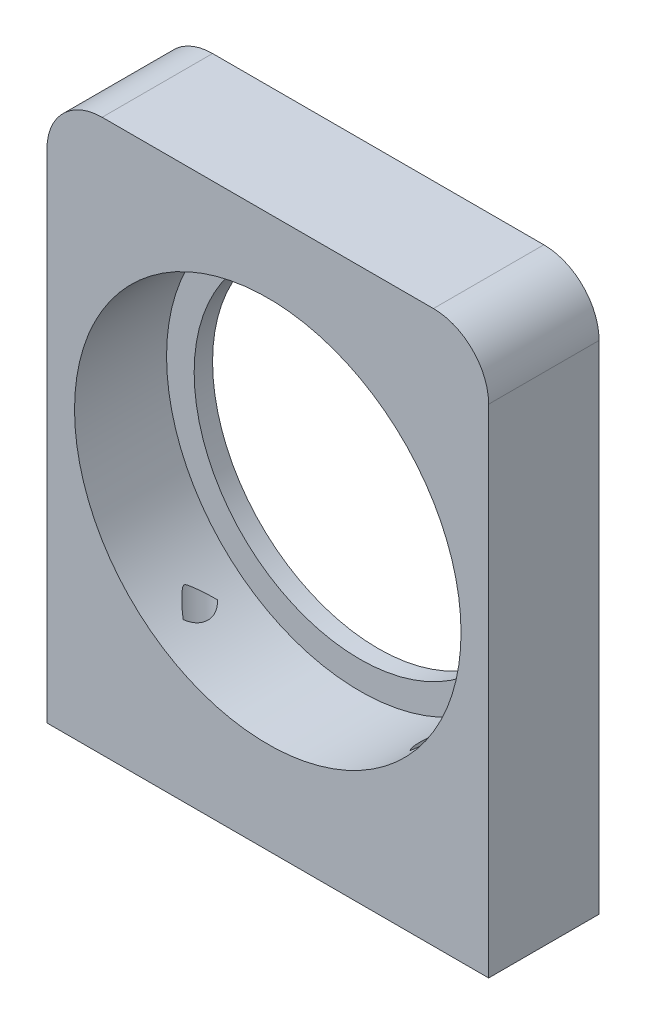
from build123d import *

# Parameters (mm, degrees)
SKIZZE1_W                       = 24
SKIZZE1_H                       = 30
AUFSATZ_LINEAR_AUSTRAGEN1_DEPTH = 3
SKIZZE2_R                       = 10.5
SCHNITT_LINEAR_AUSTRAGEN2_DEPTH = 5
SKIZZE2_3_R                     = 9
SCHNITT_LINEAR_AUSTRAGEN3_DEPTH = 7
VERRUNDUNG1_R                   = 3
M3_GEWINDEBOHRUNG1_D            = 2.5
M3_GEWINDEBOHRUNG1_DEPTH        = 7
M3_GEWINDEBOHRUNG1_TIP          = 0.751075774


with BuildPart() as part:
    # Skizze1 → Aufsatz-Linear austragen1 (new body, symmetric)
    with BuildSketch(Plane.XY):
        with Locations((0, 15)):
            Rectangle(SKIZZE1_W, SKIZZE1_H)
    extrude(amount=AUFSATZ_LINEAR_AUSTRAGEN1_DEPTH, both=True)

    # Skizze2 → Schnitt-Linear austragen2 (cut)
    with BuildSketch(Plane.XY.offset(3)):
        with Locations((0, 15.5)):
            Circle(SKIZZE2_R)
    extrude(amount=-SCHNITT_LINEAR_AUSTRAGEN2_DEPTH, mode=Mode.SUBTRACT)

    # Skizze2_3 → Schnitt-Linear austragen3 (cut, through all)
    with BuildSketch(Plane.XY.offset(3)):
        with Locations((0, 15.5)):
            Circle(SKIZZE2_3_R)
    extrude(amount=-SCHNITT_LINEAR_AUSTRAGEN3_DEPTH, mode=Mode.SUBTRACT)

    # Verrundung1
    verrundung1_edges = [part.edges().sort_by_distance(p)[0] for p in [
        (-12, 30, 0),
        (12, 30, 0),
    ]]
    fillet(verrundung1_edges, radius=VERRUNDUNG1_R)

    # M3 Gewindebohrung1
    with Locations(Plane(origin=(0, 0, 0), x_dir=(-1, 0, 0), z_dir=(0, -1, 0))):
        with Locations((-7, -0.5), (7, -0.5)):
            Hole(M3_GEWINDEBOHRUNG1_D / 2, depth=M3_GEWINDEBOHRUNG1_DEPTH)
            with Locations((0, 0, -(M3_GEWINDEBOHRUNG1_DEPTH + M3_GEWINDEBOHRUNG1_TIP / 2))):  # 118° drill point
                Cone(0, M3_GEWINDEBOHRUNG1_D / 2, M3_GEWINDEBOHRUNG1_TIP, mode=Mode.SUBTRACT)


solid = part.part
